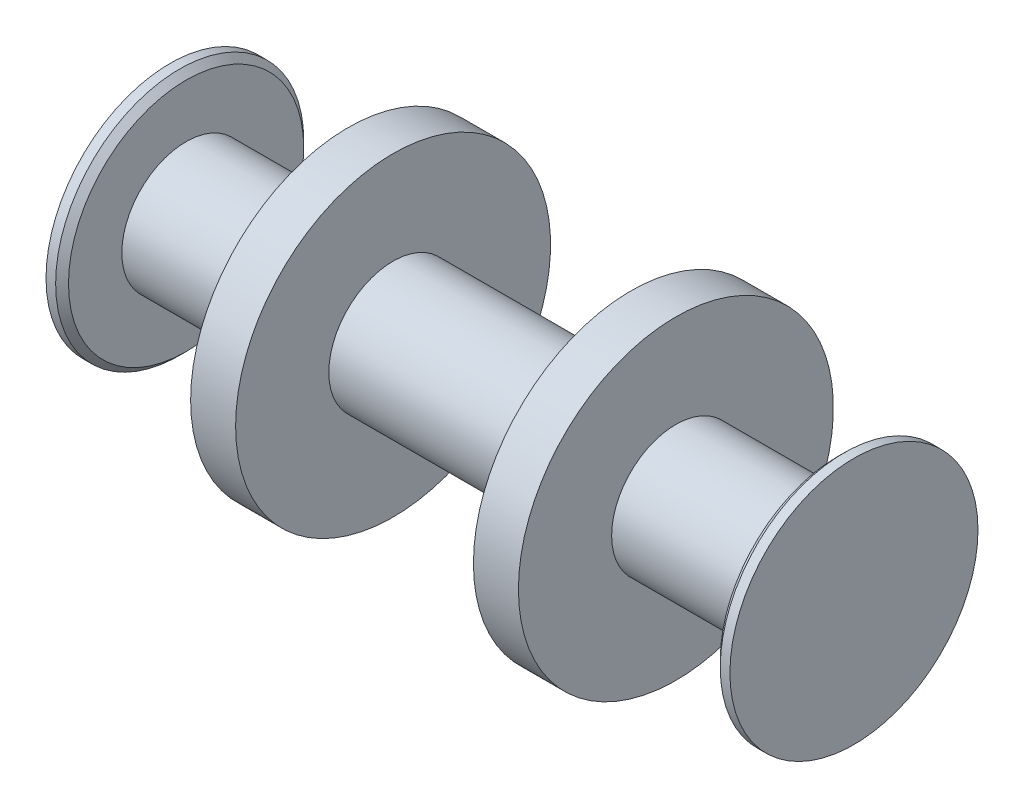
from build123d import *


with BuildPart() as part:
    # Sketch1 → Revolve1 (revolve)
    with BuildSketch(Plane.XY):
        Polygon((-135.128, 49.022), (-135.128, 0), (0, 0), (0, 25.4), (-46.99, 25.4), (-46.99, 62.23), (-64.77, 62.23), (-64.77, 25.4), (-128.778, 25.4), (-128.778, 46.482), (-131.318, 49.022), align=None)
        Polygon((0, 25.4), (0, 0), (135.128, 0), (135.128, 49.022), (131.318, 49.022), (128.778, 46.482), (128.778, 25.4), (64.77, 25.4), (64.77, 62.23), (46.99, 62.23), (46.99, 25.4), align=None)
    revolve(axis=Axis((-135.128, 0, 0), (1, 0, 0)))


solid = part.part
